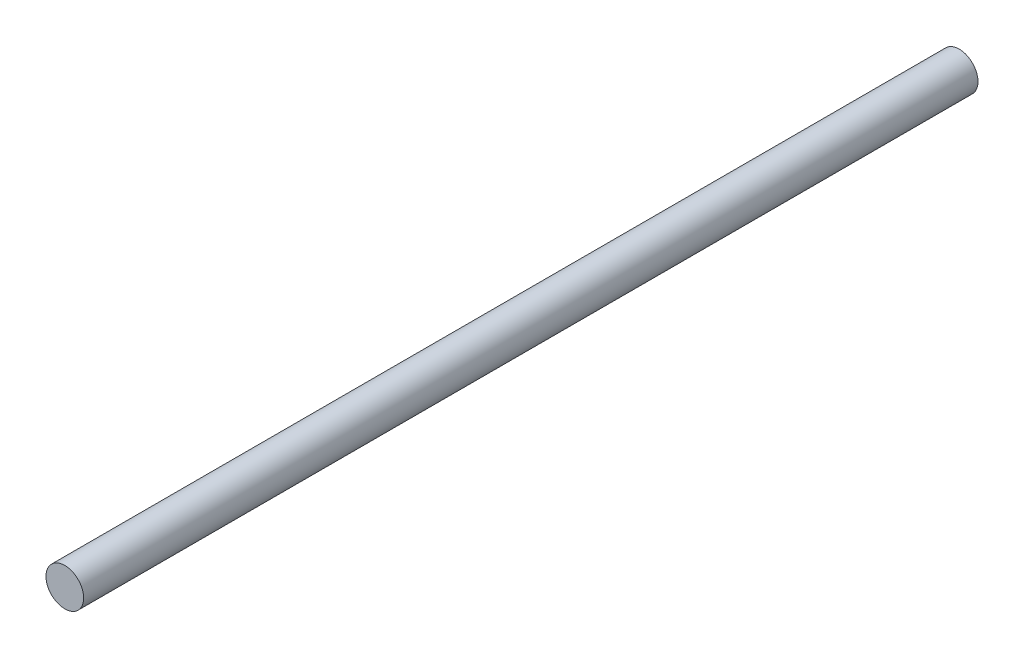
from build123d import *

# Parameters (mm, degrees)
SKETCH_2_R      = 4
EXTRUDE_2_DEPTH = 190


with BuildPart() as part:
    # ｽｹｯﾁ2 → ﾎﾞｽ - 押し出し2 (new body)
    with BuildSketch(Plane.XY.offset(12)):
        with Locations((0, 62.5)):
            Circle(SKETCH_2_R)
    extrude(amount=EXTRUDE_2_DEPTH)


solid = part.part
